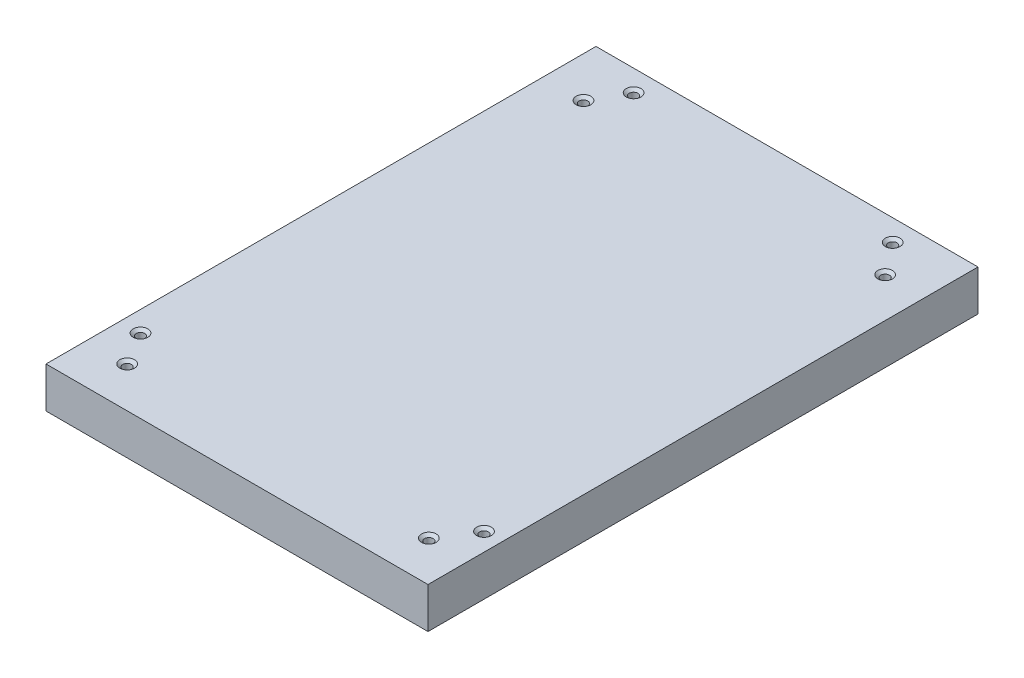
from build123d import *

# Parameters (mm, degrees)
SKETCH1_W                                         = 78.5372543
SKETCH1_H                                         = 113.08183608
BOSS_EXTRUDE1_DEPTH                               = 8.382
CSK_FOR_0_FLAT_HEAD_MACHINE_SCREW_100_D           = 1.778
CSK_FOR_0_FLAT_HEAD_MACHINE_SCREW_100_CSINK_D     = 3.0226
CSK_FOR_0_FLAT_HEAD_MACHINE_SCREW_100_CSINK_ANGLE = 100


with BuildPart() as part:
    # Sketch1 → Boss-Extrude1 (new body)
    with BuildSketch(Plane(origin=(0, 0, 0), x_dir=(1, 0, 0), z_dir=(0, 1, 0))):
        Rectangle(SKETCH1_W, SKETCH1_H)
    extrude(amount=BOSS_EXTRUDE1_DEPTH)

    # CSK for #0 Flat Head Machine Screw (100)1 (through all)
    with Locations(Plane(origin=(0, 8.382, 0), x_dir=(1, 0, 0), z_dir=(0, 1, 0))):
        with Locations((-30.928886309, 45.620107306), (31.100713455, 45.620107306), (31.100713455, -48.197514498), (-30.928886309, -48.197514498), (-35.052737817, -41.324428652), (35.568219256, -41.324428652), (26.117726217, 52.14953886), (-27.148689094, 52.14953886)):
            CounterSinkHole(CSK_FOR_0_FLAT_HEAD_MACHINE_SCREW_100_D / 2, CSK_FOR_0_FLAT_HEAD_MACHINE_SCREW_100_CSINK_D / 2, counter_sink_angle=CSK_FOR_0_FLAT_HEAD_MACHINE_SCREW_100_CSINK_ANGLE)


solid = part.part
